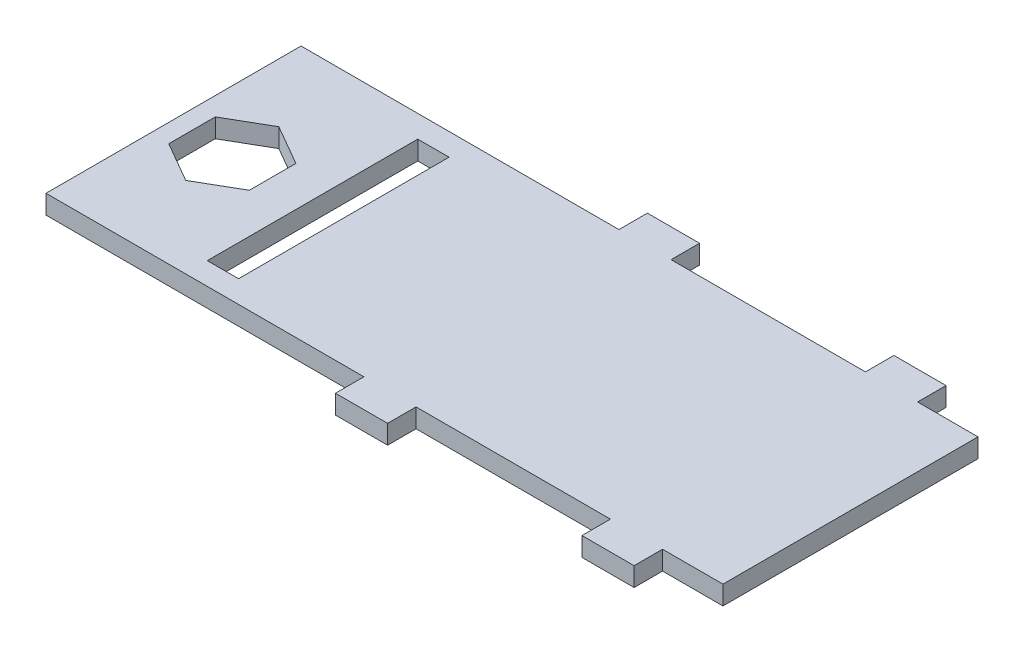
from build123d import *

# Parameters (mm, degrees)
SKETCH1_W              = 35.7
SKETCH1_H              = 13.45
BOSS_EXTRUDE1_DEPTH    = 1
SKETCH2_W              = 2.75
SKETCH2_H              = 1.5
BOSS_EXTRUDE2_DEPTH    = 1
SKETCH3_W              = 1.65
SKETCH3_H              = 11.1
ADAPTER_PCB_HOLE_DEPTH = 1
CUT_EXTRUDE2_DEPTH     = 1


with BuildPart() as part:
    # Sketch1 → Boss-Extrude1 (new body)
    with BuildSketch(Plane(origin=(0, 0, 0), x_dir=(1, 0, 0), z_dir=(0, 1, 0))):
        with Locations((-32.948423651, -12.055454233)):
            Rectangle(SKETCH1_W, SKETCH1_H)
    extrude(amount=BOSS_EXTRUDE1_DEPTH)

    # Sketch2 → Boss-Extrude2 (add)
    with BuildSketch(Plane(origin=(0, 0, 0), x_dir=(1, 0, 0), z_dir=(0, 1, 0))):
        with Locations((-32.658423651, -4.580454233)):
            Rectangle(SKETCH2_W, SKETCH2_H)
        with Locations((-32.658423651, -19.530454233)):
            Rectangle(SKETCH2_W, SKETCH2_H)
        with Locations((-19.658423651, -4.580454233)):
            Rectangle(SKETCH2_W, SKETCH2_H)
        with Locations((-19.658423651, -19.530454233)):
            Rectangle(SKETCH2_W, SKETCH2_H)
    extrude(amount=BOSS_EXTRUDE2_DEPTH)

    # Sketch3 → adapter_PCB_hole (cut)
    with BuildSketch(Plane(origin=(0, 0, 0), x_dir=(-1, 0, 0), z_dir=(0, -1, 0))):
        with Locations((42.643423651, -12.055454233)):
            Rectangle(SKETCH3_W, SKETCH3_H)
    extrude(amount=-ADAPTER_PCB_HOLE_DEPTH, mode=Mode.SUBTRACT)

    # Sketch4 → Cut-Extrude2 (cut)
    with BuildSketch(Plane(origin=(0, 0, 0), x_dir=(-1, 0, 0), z_dir=(0, -1, 0))):
        Polygon((49.823423651, -13.282323555), (49.823423651, -10.828584911), (47.698423651, -9.601715589), (45.573423651, -10.828584911), (45.573423651, -13.282323555), (47.698423651, -14.509192877), align=None)
    extrude(amount=-CUT_EXTRUDE2_DEPTH, mode=Mode.SUBTRACT)


solid = part.part
